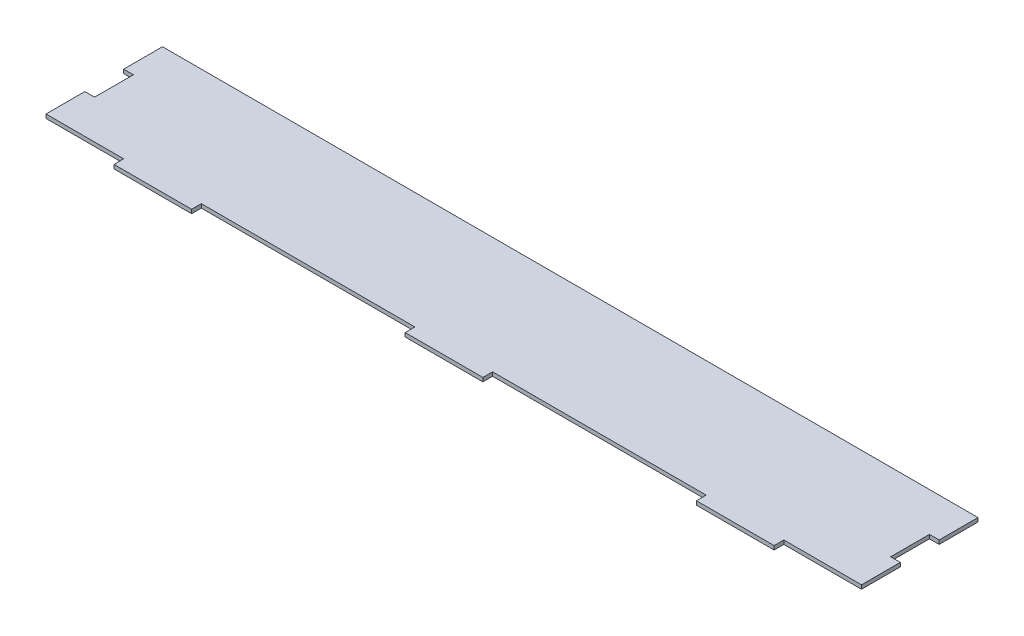
from build123d import *

# Parameters (mm, degrees)
BOSS_EXTRUDE1_DEPTH = 2.54


with BuildPart() as part:
    # Sketch1 → Boss-Extrude1 (new body)
    with BuildSketch(Plane(origin=(0, 0, 0), x_dir=(1, 0, 0), z_dir=(0, 1, 0))):
        Polygon((292.1, -76.2), (292.1, -82.55), (241.3, -82.55), (241.3, -76.2), (101.6, -76.2), (101.6, -82.55), (50.8, -82.55), (50.8, -76.2), (0, -76.2), (0, -50.8), (6.35, -50.8), (6.35, -25.4), (0, -25.4), (0, 0), (533.4, 0), (533.4, -25.4), (527.05, -25.4), (527.05, -50.8), (533.4, -50.8), (533.4, -76.2), (482.6, -76.2), (482.6, -82.55), (431.8, -82.55), (431.8, -76.2), align=None)
    extrude(amount=BOSS_EXTRUDE1_DEPTH)


solid = part.part
